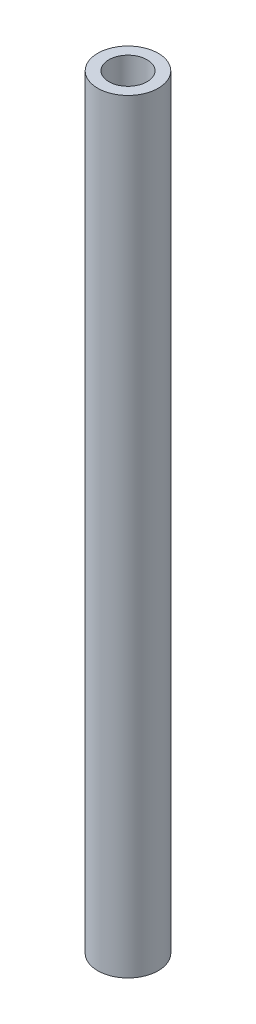
from build123d import *

# Parameters (mm, degrees)
CROQUIS1_R              = 1.585
CROQUIS1_R_2            = 1
SALIENTE_EXTRUIR1_DEPTH = 40


with BuildPart() as part:
    # Croquis1 → Saliente-Extruir1 (new body)
    with BuildSketch(Plane(origin=(0, 0, 0), x_dir=(1, 0, 0), z_dir=(0, 1, 0))):
        Circle(CROQUIS1_R)
        Circle(CROQUIS1_R_2, mode=Mode.SUBTRACT)
    extrude(amount=SALIENTE_EXTRUIR1_DEPTH)


solid = part.part
